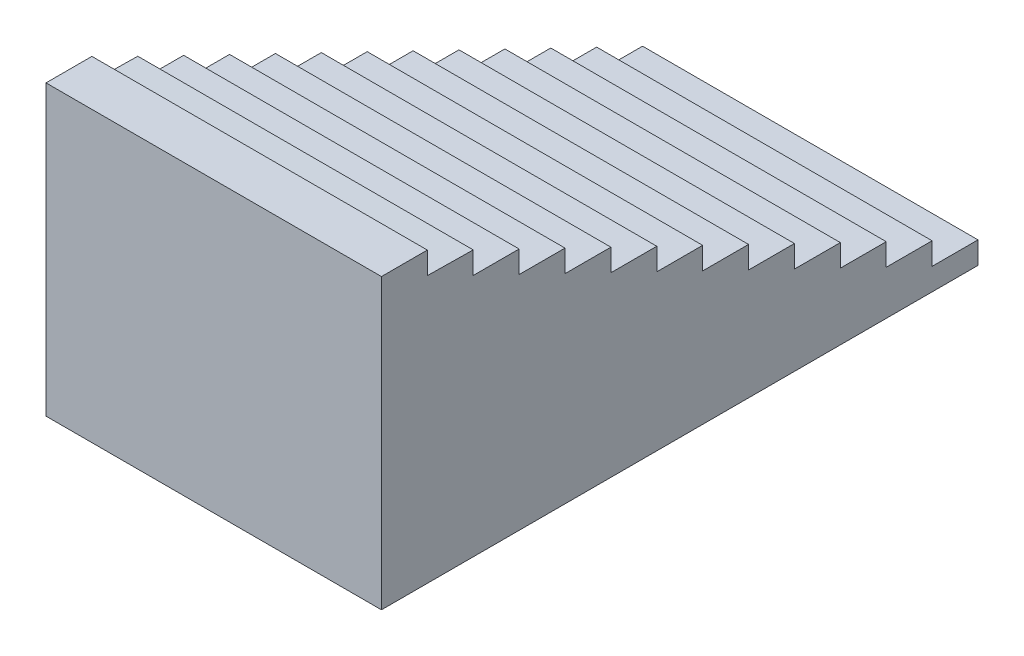
from build123d import *

# Parameters (mm, degrees)
BOSS_EXTRUDE1_DEPTH = 2120


with BuildPart() as part:
    # Sketch1 → Boss-Extrude1 (new body)
    with BuildSketch(Plane(origin=(0, 0, 0), x_dir=(0, 0, -1), z_dir=(1, 0, 0))):
        Polygon((-350, 195.21314577), (-60, 195.21314577), (-60, 55.21314577), (229.9707266, 51.09274351), (229.9707266, -88.90725649), (519.9707266, -88.90725649), (519.9707266, -228.90725649), (809.9707266, -228.90725649), (809.9707266, -368.90725649), (1099.9707266, -368.90725649), (1099.9707266, -508.90725649), (1389.9707266, -508.90725649), (1389.9707266, -648.90725649), (1679.9707266, -648.90725649), (1679.9707266, -788.90725649), (1969.9707266, -788.90725649), (1969.9707266, -928.90725649), (2259.9707266, -928.90725649), (2259.9707266, -1068.90725649), (2549.9707266, -1068.90725649), (2549.9707266, -1208.90725649), (2839.9707266, -1208.90725649), (2839.9707266, -1348.90725649), (3129.9707266, -1348.90725649), (3129.9707266, -1488.90725649), (3419.9707266, -1488.90725649), (3419.9707266, -1628.90725649), (-350, -1628.90725649), align=None)
    extrude(amount=-BOSS_EXTRUDE1_DEPTH)


solid = part.part
